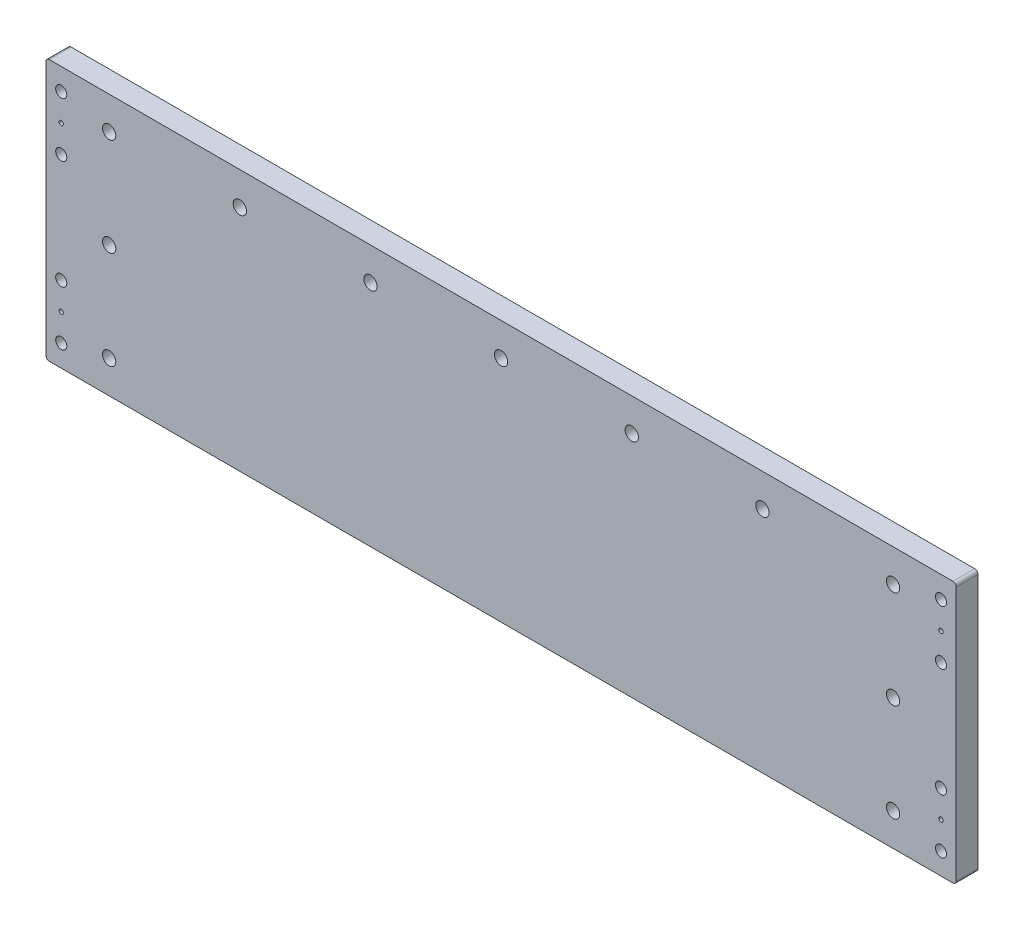
from build123d import *

# Parameters (mm, degrees)
SKETCH1_W                 = 418
SKETCH1_H                 = 120
BOSS_EXTRUDE1_DEPTH       = 5
SKETCH3_R                 = 3.05
CUT_EXTRUDE2_DEPTH        = 11
FILLET1_R                 = 1.5
SKETCH4_R                 = 2.55
SKETCH4_R_2               = 1
CUT_EXTRUDE3_DEPTH        = 11
MIRROR2_COPY_1_SKETCH_R   = 2.55
MIRROR2_COPY_1_SKETCH_R_2 = 1
MIRROR2_COPY_1_DEPTH      = 11


with BuildPart() as part:
    # Sketch1 → Boss-Extrude1 (new body, symmetric)
    with BuildSketch(Plane.XY):
        Rectangle(SKETCH1_W, SKETCH1_H)
    extrude(amount=BOSS_EXTRUDE1_DEPTH, both=True)

    # Sketch3 → Cut-Extrude2 (cut, through all)
    with BuildSketch(Plane.XY.offset(5)):
        with Locations((-180, 45)):
            Circle(SKETCH3_R)
        with Locations((180, 45)):
            Circle(SKETCH3_R)
        with Locations((180, -45)):
            Circle(SKETCH3_R)
        with Locations((-180, -45)):
            Circle(SKETCH3_R)
        with Locations((0, 45)):
            Circle(SKETCH3_R)
        with Locations((-120, 45)):
            Circle(SKETCH3_R)
        with Locations((120, 45)):
            Circle(SKETCH3_R)
        with Locations((-180, 0)):
            Circle(SKETCH3_R)
        with Locations((-60, 45)):
            Circle(SKETCH3_R)
        with Locations((60, 45)):
            Circle(SKETCH3_R)
        with Locations((180, 0)):
            Circle(SKETCH3_R)
    extrude(amount=-CUT_EXTRUDE2_DEPTH, mode=Mode.SUBTRACT)

    # Fillet1
    fillet1_edges = [part.edges().sort_by_distance(p)[0] for p in [
        (-209, 60, 0),
        (209, 60, 0),
        (209, -60, 0),
        (-209, -60, 0),
    ]]
    fillet(fillet1_edges, radius=FILLET1_R)

    # Sketch4 → Cut-Extrude3 (cut, through all)
    with BuildSketch(Plane.XY.offset(5)):
        with Locations((-202, 50)):
            Circle(SKETCH4_R)
        with Locations((-202, 37.5)):
            Circle(SKETCH4_R_2)
        with Locations((-202, 25)):
            Circle(SKETCH4_R)
    cut_extrude3 = extrude(amount=-CUT_EXTRUDE3_DEPTH, mode=Mode.SUBTRACT)

    # Mirror1: Cut-Extrude3 across plane
    add(cut_extrude3.mirror(Plane.ZX), mode=Mode.SUBTRACT)

    # Mirror2: Cut-Extrude3 across plane
    add(cut_extrude3.mirror(Plane(origin=(0, 0, 0), x_dir=(0, 0, 1), z_dir=(1, 0, 0))), mode=Mode.SUBTRACT)

    # Mirror2 copy 1 sketch → Mirror2 copy 1 (cut, through all)
    with BuildSketch(Plane(origin=(0, 0, 5), x_dir=(-1, 0, 0), z_dir=(0, 0, 1))):
        with Locations((-202, 50)):
            Circle(MIRROR2_COPY_1_SKETCH_R)
        with Locations((-202, 37.5)):
            Circle(MIRROR2_COPY_1_SKETCH_R_2)
        with Locations((-202, 25)):
            Circle(MIRROR2_COPY_1_SKETCH_R)
    extrude(amount=-MIRROR2_COPY_1_DEPTH, mode=Mode.SUBTRACT)


solid = part.part
